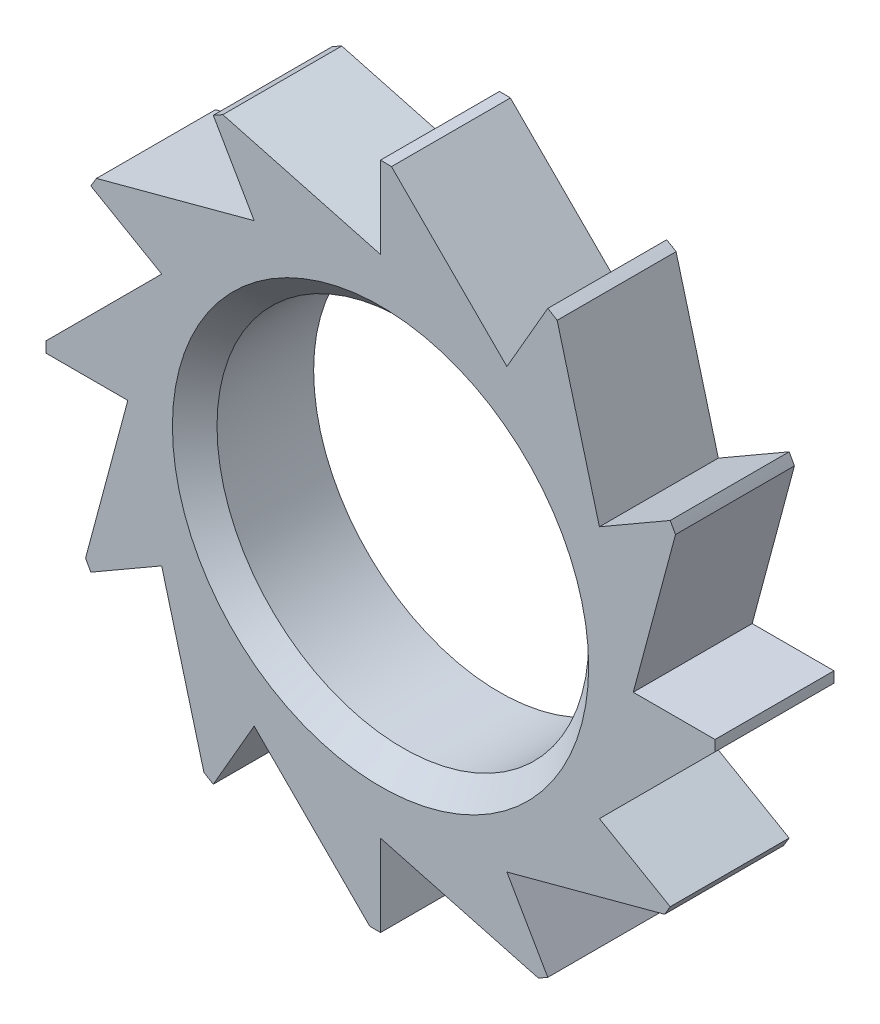
from build123d import *

# Parameters (mm, degrees)
SKETCH1_R           = 45
SKETCH1_R_2         = 25
BOSS_EXTRUDE1_DEPTH = 8
CHAMFER1_SIZE       = 3
CUT_EXTRUDE1_START  = -17
CUT_EXTRUDE1_DEPTH  = 18
CIRPATTERN1_COUNT   = 12


with BuildPart() as part:
    # Sketch1 → Boss-Extrude1 (new body, symmetric)
    with BuildSketch(Plane.XY):
        Circle(SKETCH1_R)
        Circle(SKETCH1_R_2, mode=Mode.SUBTRACT)
    extrude(amount=BOSS_EXTRUDE1_DEPTH, both=True)

    # Chamfer1
    chamfer1_edges = [part.edges().sort_by_distance(p)[0] for p in [
        (-25, 0, 8),
    ]]
    chamfer(chamfer1_edges, length=CHAMFER1_SIZE)

    # Sketch2 → Cut-Extrude1 (cut)
    with BuildSketch(Plane.XY.offset(8).offset(CUT_EXTRUDE1_START)):
        with BuildLine():
            Line((0, 45), (0, 34))
            Line((0, 34), (-21.215955949, 39.684798263))
            ThreePointArc((-21.215955949, 39.684798263), (-10.935814514, 43.650978923), (0, 45))
        make_face()
    cut_extrude1 = extrude(amount=CUT_EXTRUDE1_DEPTH, mode=Mode.SUBTRACT)

    # CirPattern1: Cut-Extrude1 ×12 about axis
    cirpattern1_axis = Axis((0, 0, 0), (0, 0, 1))
    for i in range(1, CIRPATTERN1_COUNT):
        add(cut_extrude1.rotate(cirpattern1_axis, i * 360 / CIRPATTERN1_COUNT), mode=Mode.SUBTRACT)


solid = part.part
